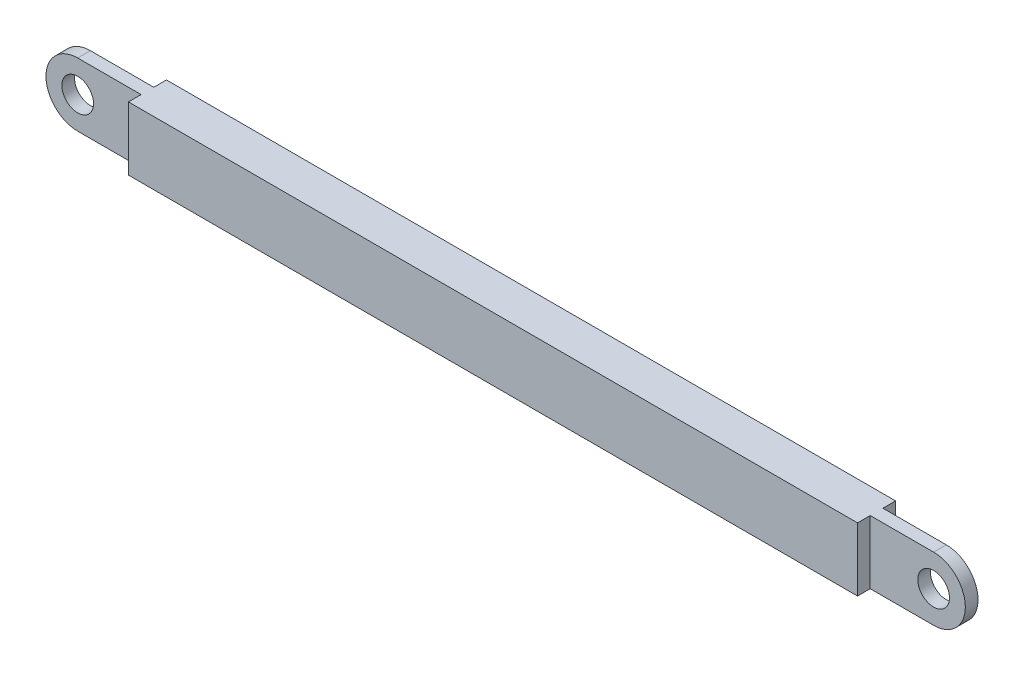
from build123d import *

# Parameters (mm, degrees)
SKETCH19_W          = 115
SKETCH19_H          = 10
BOSS_EXTRUDE4_DEPTH = 3
SKETCH22_R          = 2.5
BOSS_EXTRUDE5_DEPTH = 1


with BuildPart() as part:
    # Sketch19 → Boss-Extrude4 (new body, symmetric)
    with BuildSketch(Plane.XY):
        Rectangle(SKETCH19_W, SKETCH19_H)
    boss_extrude4 = extrude(amount=BOSS_EXTRUDE4_DEPTH, both=True)

    # Sketch22 → Boss-Extrude5 (add, symmetric)
    with BuildSketch(Plane.XY):
        with BuildLine():
            Line((57.5, 5), (67.5, 5))
            ThreePointArc((67.5, 5), (72.5, 0), (67.5, -5))
            Line((67.5, -5), (57.5, -5))
            Line((57.5, -5), (57.5, 5))
        make_face()
        with Locations((67.5, 0)):
            Circle(SKETCH22_R, mode=Mode.SUBTRACT)
    boss_extrude5 = extrude(amount=BOSS_EXTRUDE5_DEPTH, both=True)

    # Mirror1: Boss-Extrude4, Boss-Extrude5 across plane
    add(boss_extrude4.mirror(Plane(origin=(0, 0, 0), x_dir=(0, 0, 1), z_dir=(1, 0, 0))))
    add(boss_extrude5.mirror(Plane(origin=(0, 0, 0), x_dir=(0, 0, 1), z_dir=(1, 0, 0))))


solid = part.part
